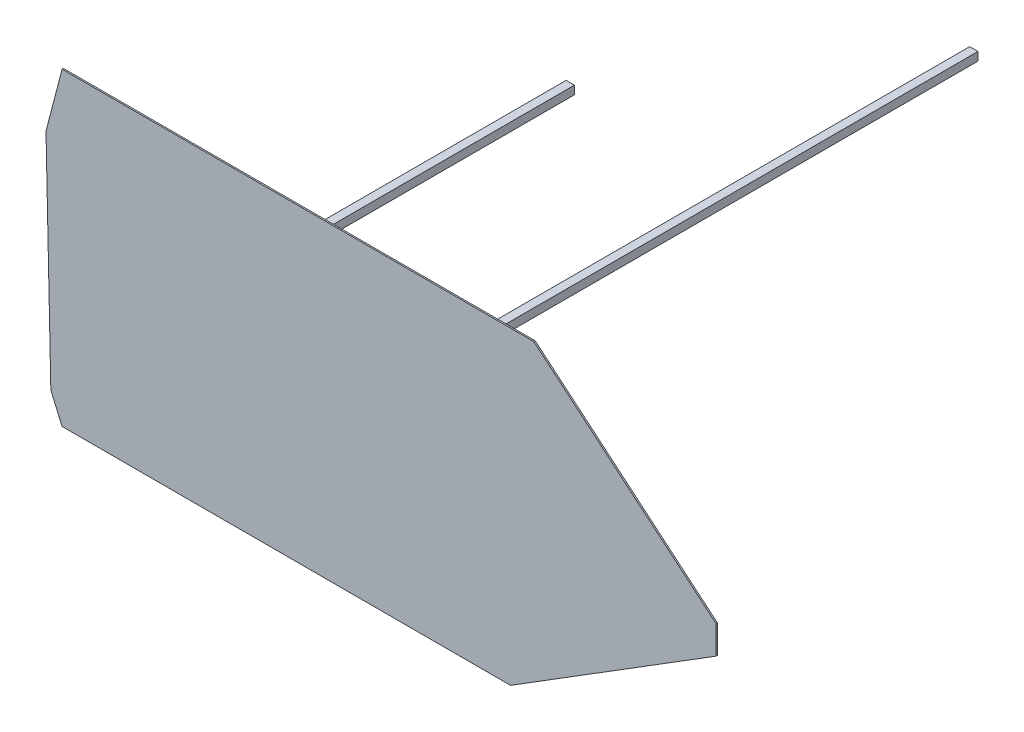
from build123d import *

# Parameters (mm, degrees)
ESQUISSE1_W          = 50
ESQUISSE1_H          = 50
BOSS_EXTRU_1_DEPTH   = 5
BOSS_EXTRU_2_DEPTH   = 5
ESQUISSE3_W          = 6
ESQUISSE3_H          = 6
BOSS_EXTRU_3_DEPTH   = 350
BOSS_EXTRU_3_2_DEPTH = 350
BOSS_EXTRU_4_DEPTH   = 1


with BuildPart() as part:
    # Esquisse1 → Boss.-Extru.1 (new body)
    with BuildSketch(Plane.XY):
        with Locations((25, 25)):
            Rectangle(ESQUISSE1_W, ESQUISSE1_H)
    extrude(amount=BOSS_EXTRU_1_DEPTH)

    # Esquisse2 → Boss.-Extru.2 (add)
    with BuildSketch(Plane.XY.offset(5)):
        Polygon((-5.653453017, 9.333236963), (57.285195489, 53.463556126), (231.691551155, 53.463556126), (285.93578731, -3.052689921), (284, -82.509595771), (207.706196647, -129.761060536), (50.431516213, -129.761060536), (-5.653453017, -85.386571632), align=None)
    extrude(amount=-BOSS_EXTRU_2_DEPTH)

    # Esquisse4 → Boss.-Extru.4 (add)
    with BuildSketch(Plane.XY.offset(5)):
        Polygon((-12.279278661, 66.048069058), (326.72770214, 66.048069058), (457.703171695, -44.043166729), (457.703171695, -64.294776841), (309.993915216, -156.325656643), (-12.279278661, -156.325656643), (-20.370490615, -137.774738612), (-23.847853986, 21.701863644), align=None)
    extrude(amount=BOSS_EXTRU_4_DEPTH)


with BuildPart() as body_2:
    # Esquisse3 → Boss.-Extru.3 (new body)
    with BuildSketch(Plane(origin=(0, 0, 0), x_dir=(-1, 0, 0), z_dir=(0, 0, -1))):
        with Locations((3, -118.721693301)):
            Rectangle(ESQUISSE3_W, ESQUISSE3_H)
    extrude(amount=BOSS_EXTRU_3_DEPTH)


with BuildPart() as body_3:
    # Esquisse3 → Boss.-Extru.3 2 (new body)
    with BuildSketch(Plane(origin=(0, 0, 0), x_dir=(-1, 0, 0), z_dir=(0, 0, -1))):
        with Locations((-287, 47.238939464)):
            Rectangle(ESQUISSE3_W, ESQUISSE3_H)
    extrude(amount=BOSS_EXTRU_3_2_DEPTH)


solid = Compound([part.part, body_2.part, body_3.part])
